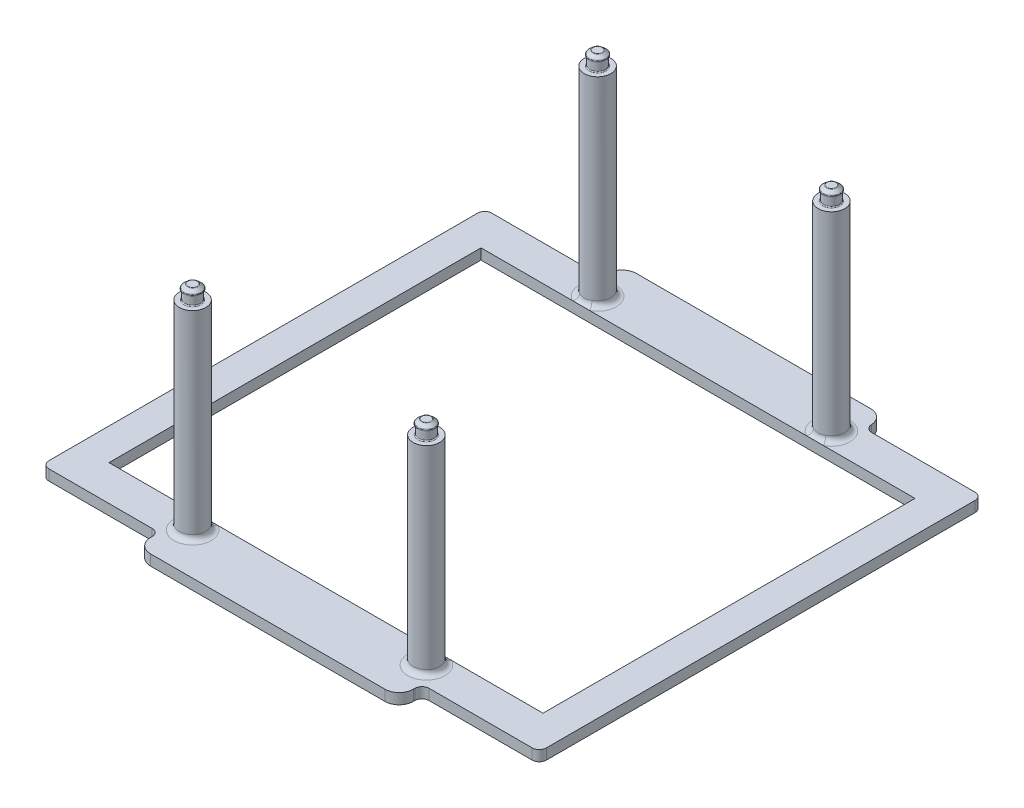
from build123d import *

# Parameters (mm, degrees)
BOSS_EXTRUDE1_DEPTH   = 2.4
SKETCH2_W             = 98
SKETCH2_H             = 84
CUT_EXTRUDE1_DEPTH    = 2.4
SKETCH3_R             = 3
BOSS_EXTRUDE2_DEPTH   = 45
FILLET1_R             = 1.2
FILLET2_R             = 3.2
FILLET3_R             = 1.6
SKETCH4_R             = 1.75
BOSS_EXTRUDE3_DEPTH   = 2.14
SKETCH5_R             = 1.94
SKETCH5_R_2           = 1.97455384
BOSS_EXTRUDE4_DEPTH   = 1
CHAMFER1_SIZE         = 0.75
CHAMFER1_SIZE2        = 0.893815194
CHAMFER1_PART_2_SIZE  = 0.75
CHAMFER1_PART_2_SIZE2 = 0.893815194
CHAMFER1_PART_3_SIZE  = 0.75
CHAMFER1_PART_3_SIZE2 = 0.893815194
CHAMFER1_PART_4_SIZE  = 0.75
CHAMFER1_PART_4_SIZE2 = 0.893815194
FILLET4_R             = 0.2
SCALE1_SCALE          = 1.15


with BuildPart() as part:
    # Sketch1 → Boss-Extrude1 (new body)
    with BuildSketch(Plane(origin=(0, 0, 0), x_dir=(1, 0, 0), z_dir=(0, 1, 0))):
        Polygon((29.66540709, 50), (29.66540709, 54.536741214), (-29.66540709, 54.536741214), (-29.66540709, 50), (-56.164389137, 50), (-56.164389137, -50), (-29.66540709, -50), (-29.66540709, -55.151425996), (29.66540709, -55.151425996), (29.66540709, -50), (56.164389137, -50), (56.164389137, 50), align=None)
    extrude(amount=BOSS_EXTRUDE1_DEPTH)

    # Sketch2 → Cut-Extrude1 (cut)
    with BuildSketch(Plane(origin=(0, 2.4, 0), x_dir=(1, 0, 0), z_dir=(0, 1, 0))):
        Rectangle(SKETCH2_W, SKETCH2_H)
    extrude(amount=-CUT_EXTRUDE1_DEPTH, mode=Mode.SUBTRACT)

    # Sketch3 → Boss-Extrude2 (add)
    with BuildSketch(Plane(origin=(0, 2.4, 0), x_dir=(1, 0, 0), z_dir=(0, 1, 0))):
        with Locations((-26.4, 45.72614132)):
            Circle(SKETCH3_R)
        with Locations((26.4, 45.72614132)):
            Circle(SKETCH3_R)
        with Locations((-26.4, -45.72614132)):
            Circle(SKETCH3_R)
        with Locations((26.4, -45.72614132)):
            Circle(SKETCH3_R)
    extrude(amount=BOSS_EXTRUDE2_DEPTH)

    # Fillet1
    fillet1_edges = [part.edges().sort_by_distance(p)[0] for p in [
        (-29.4, 2.4, -45.72614132),
        (23.4, 2.4, -45.72614132),
        (-29.4, 2.4, 45.72614132),
        (23.4, 2.4, 45.72614132),
    ]]
    fillet(fillet1_edges, radius=FILLET1_R)

    # Fillet2
    fillet2_edges = [part.edges().sort_by_distance(p)[0] for p in [
        (-29.66540709, 1.2, -54.536741214),
        (29.66540709, 1.2, -54.536741214),
        (29.66540709, 1.2, 55.151425996),
        (-29.66540709, 1.2, 55.151425996),
    ]]
    fillet(fillet2_edges, radius=FILLET2_R)

    # Fillet3
    fillet3_edges = [part.edges().sort_by_distance(p)[0] for p in [
        (-56.164389137, 1.2, -50),
        (-29.66540709, 1.2, -50),
        (56.164389137, 1.2, -50),
        (29.66540709, 1.2, -50),
        (29.66540709, 1.2, 50),
        (56.164389137, 1.2, 50),
        (-29.66540709, 1.2, 50),
        (-56.164389137, 1.2, 50),
    ]]
    fillet(fillet3_edges, radius=FILLET3_R)

    # Sketch4 → Boss-Extrude3 (add)
    with BuildSketch(Plane(origin=(0, 47.4, 0), x_dir=(1, 0, 0), z_dir=(0, 1, 0))):
        with Locations((-26.4, 45.72614132)):
            Circle(SKETCH4_R)
        with Locations((26.4, 45.72614132)):
            Circle(SKETCH4_R)
        with Locations((26.4, -45.72614132)):
            Circle(SKETCH4_R)
        with Locations((-26.4, -45.72614132)):
            Circle(SKETCH4_R)
    extrude(amount=BOSS_EXTRUDE3_DEPTH)

    # Sketch5 → Boss-Extrude4 (add)
    with BuildSketch(Plane(origin=(0, 49.54, 0), x_dir=(1, 0, 0), z_dir=(0, 1, 0))):
        with Locations((-26.4, 45.72614132)):
            Circle(SKETCH5_R)
        with Locations((26.392405847, 45.72614132)):
            Circle(SKETCH5_R)
        with Locations((26.392405847, -45.747296604)):
            Circle(SKETCH5_R)
        with Locations((-26.4, -45.72614132)):
            Circle(SKETCH5_R_2)
    extrude(amount=BOSS_EXTRUDE4_DEPTH)

    # Chamfer1
    chamfer1_edges = [part.edges().sort_by_distance(p)[0] for p in [
        (-28.34, 50.54, -45.72614132),
    ]]
    chamfer1_side = [part.faces().sort_by_distance(p)[0] for p in [
        (-28.34, 50.04, -45.72614132),
    ]]
    chamfer(chamfer1_edges, length=CHAMFER1_SIZE, length2=CHAMFER1_SIZE2, reference=chamfer1_side[0])

    # Chamfer1 part 2
    chamfer1_part_2_edges = [part.edges().sort_by_distance(p)[0] for p in [
        (24.452405847, 50.54, -45.72614132),
    ]]
    chamfer1_part_2_side = [part.faces().sort_by_distance(p)[0] for p in [
        (24.452405847, 50.04, -45.72614132),
    ]]
    chamfer(chamfer1_part_2_edges, length=CHAMFER1_PART_2_SIZE, length2=CHAMFER1_PART_2_SIZE2, reference=chamfer1_part_2_side[0])

    # Chamfer1 part 3
    chamfer1_part_3_edges = [part.edges().sort_by_distance(p)[0] for p in [
        (24.452405847, 50.54, 45.747296604),
    ]]
    chamfer1_part_3_side = [part.faces().sort_by_distance(p)[0] for p in [
        (24.452405847, 50.04, 45.747296604),
    ]]
    chamfer(chamfer1_part_3_edges, length=CHAMFER1_PART_3_SIZE, length2=CHAMFER1_PART_3_SIZE2, reference=chamfer1_part_3_side[0])

    # Chamfer1 part 4
    chamfer1_part_4_edges = [part.edges().sort_by_distance(p)[0] for p in [
        (-28.37455384, 50.54, 45.72614132),
    ]]
    chamfer1_part_4_side = [part.faces().sort_by_distance(p)[0] for p in [
        (-28.37455384, 50.04, 45.72614132),
    ]]
    chamfer(chamfer1_part_4_edges, length=CHAMFER1_PART_4_SIZE, length2=CHAMFER1_PART_4_SIZE2, reference=chamfer1_part_4_side[0])

    # Fillet4
    fillet4_edges = [part.edges().sort_by_distance(p)[0] for p in [
        (-28.15, 47.4, -45.72614132),
        (24.65, 47.4, -45.72614132),
        (24.65, 47.4, 45.72614132),
        (-28.15, 47.4, 45.72614132),
        (-27.480738646, 50.54, 45.72614132),
        (-28.37455384, 49.79, 45.72614132),
        (25.346221042, 50.54, 45.747296604),
        (24.452405847, 49.79, 45.747296604),
        (25.346221042, 50.54, -45.72614132),
        (24.452405847, 49.79, -45.72614132),
        (-27.446184806, 50.54, -45.72614132),
        (-28.34, 49.79, -45.72614132),
    ]]
    fillet(fillet4_edges, radius=FILLET4_R)


with BuildPart() as part_1:
    # Scale1: scaled about (-0.000682604, 10.351550459, 0.348975247)
    add(part.part.scale(SCALE1_SCALE).moved(Location((0.000102391, -1.552732569, -0.052346287))))


solid = part_1.part
